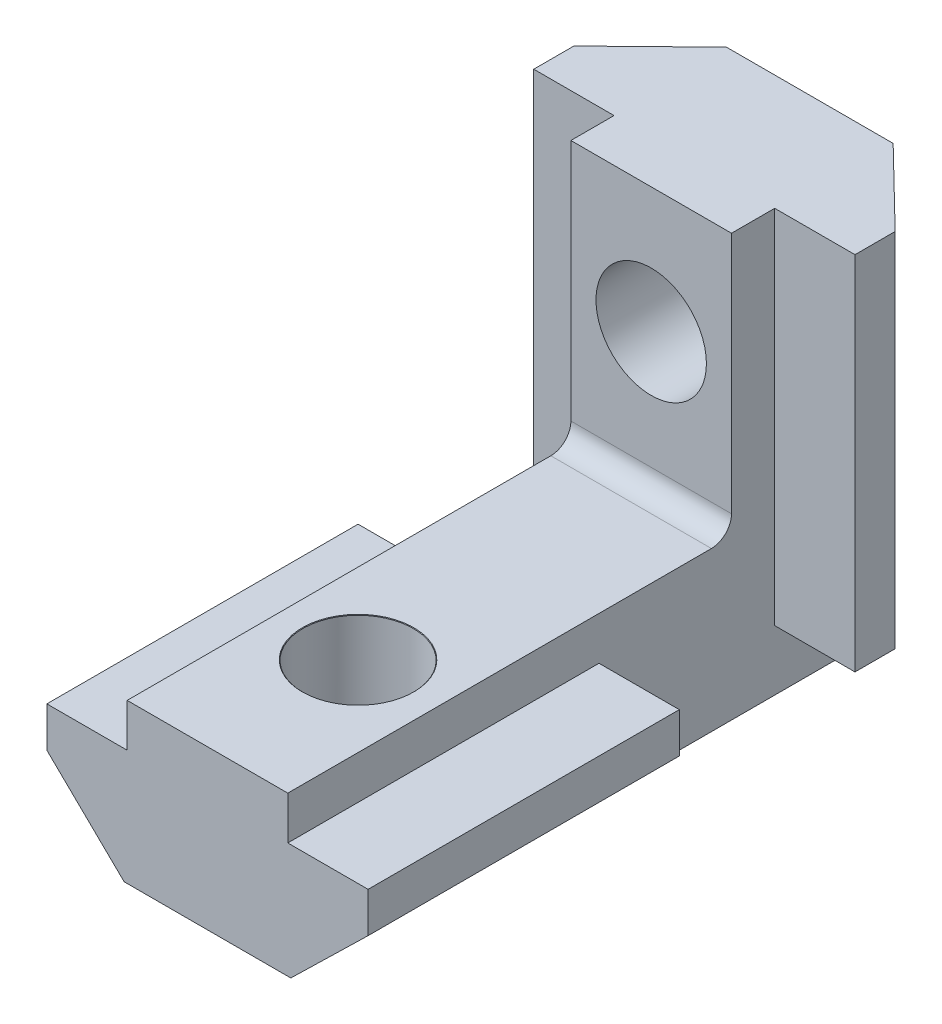
from build123d import *

# Parameters (mm, degrees)
ESTRUSIONE_ESTRUSIONE1_DEPTH   = 15.5
SCHIZZO2_W                     = 8
SCHIZZO2_H                     = 7.9
ESTRUSIONE_ESTRUSIONE2_DEPTH   = 14.5
ESTRUSIONE_ESTRUSIONE3_DEPTH   = 18
RACCORDO1_R                    = 1
FORO_PER_VITE_M5_1_D           = 5.5
FORO_PER_VITE_M5_1_DEPTH       = 7.9
FORO_PER_VITE_M5_1_CSINK_D     = 5.55
FORO_PER_VITE_M5_1_CSINK_ANGLE = 90
FORO_PER_VITE_M5_2_D           = 5.5


with BuildPart() as part:
    # Schizzo1 → Estrusione-Estrusione1 (new body)
    with BuildSketch(Plane.XY):
        Polygon((-4.15, 0), (4.15, 0), (8, 3.75), (8, 5.75), (4, 5.75), (4, 7.9), (-4, 7.9), (-4, 5.75), (-8, 5.75), (-8, 3.75), align=None)
    extrude(amount=-ESTRUSIONE_ESTRUSIONE1_DEPTH)

    # Schizzo2 → Estrusione-Estrusione2 (add)
    with BuildSketch(Plane(origin=(0, 0, -15.5), x_dir=(-1, 0, 0), z_dir=(0, 0, -1))):
        with Locations((0, 3.95)):
            Rectangle(SCHIZZO2_W, SCHIZZO2_H)
    extrude(amount=ESTRUSIONE_ESTRUSIONE2_DEPTH)

    # Schizzo4 → Estrusione-Estrusione3 (add)
    with BuildSketch(Plane(origin=(0, 21, 0), x_dir=(-1, 0, 0), z_dir=(0, -1, 0))):
        Polygon((-4.15, 30), (4.15, 30), (8, 26.25), (8, 24.25), (4, 24.25), (4, 22.1), (-4, 22.1), (-4, 24.25), (-8, 24.25), (-8, 26.25), align=None)
    extrude(amount=ESTRUSIONE_ESTRUSIONE3_DEPTH)

    # Raccordo1
    raccordo1_edges = [part.edges().sort_by_distance(p)[0] for p in [
        (0, 7.9, -22.1),
    ]]
    fillet(raccordo1_edges, radius=RACCORDO1_R)

    # Foro per Vite M5-1
    with Locations(Plane(origin=(0, 7.9, 0), x_dir=(1, 0, 0), z_dir=(0, 1, 0))):
        with Locations((0, 7.5)):
            CounterSinkHole(FORO_PER_VITE_M5_1_D / 2, FORO_PER_VITE_M5_1_CSINK_D / 2, depth=FORO_PER_VITE_M5_1_DEPTH, counter_sink_angle=FORO_PER_VITE_M5_1_CSINK_ANGLE)

    # Foro per Vite M5-2 (through all)
    with Locations(Plane.XY.offset(-22.1)):
        with Locations((0, 14.75)):
            Hole(FORO_PER_VITE_M5_2_D / 2)


solid = part.part
